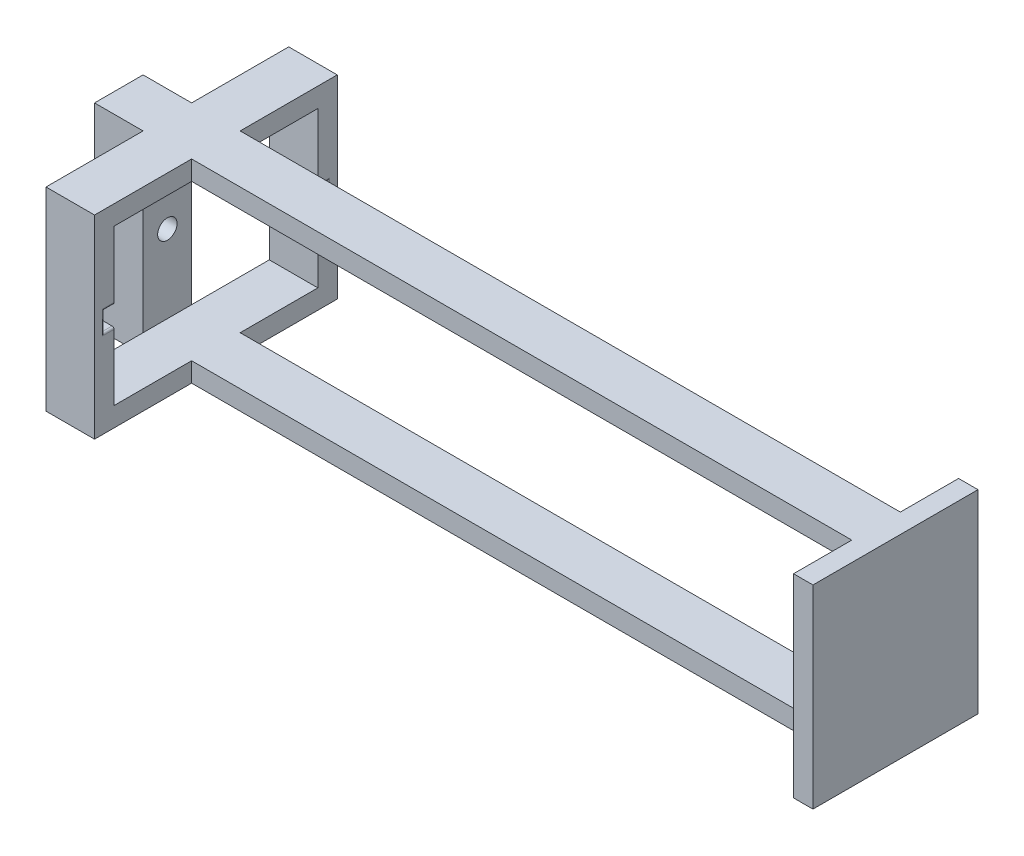
from build123d import *

# Parameters (mm, degrees)
SKETCH1_W            = 101.6
SKETCH1_H            = 25.4
BOSS_EXTRUDE1_DEPTH  = 3.175
BOSS_EXTRUDE2_DEPTH  = 6.35
SKETCH4_W            = 6.35
SKETCH4_H            = 2.54
CUT_EXTRUDE2_DEPTH   = 1.27
FILLET2_R            = 0.254
FILLET3_R            = 0.254
FILLET2_OF_MIRROR4_R = 0.254
FILLET3_OF_MIRROR4_R = 0.254
SKETCH6_W            = 7.62
SKETCH6_H            = 25.4
BOSS_EXTRUDE4_DEPTH  = 2.54
CUT_EXTRUDE3_REACH   = 21.05
SKETCH7_W            = 92.71
SKETCH7_H            = 20.32
CUT_EXTRUDE4_REACH   = 103.6
SKETCH8_R            = 1.27


with BuildPart() as part:
    # Sketch1 → Boss-Extrude1 (new body, symmetric)
    with BuildSketch(Plane.XY):
        with Locations((50.8, 0)):
            Rectangle(SKETCH1_W, SKETCH1_H)
    extrude(amount=BOSS_EXTRUDE1_DEPTH, both=True)

    # Sketch2 → Boss-Extrude2 (add)
    with BuildSketch(Plane.ZY.offset(-12.7)):
        Polygon((-3.175, 12.7), (-15.875, 12.7), (-15.875, -12.7), (-3.175, -12.7), (-3.175, -10.16), (-13.335, -10.16), (-13.335, 10.16), (-3.175, 10.16), align=None)
    boss_extrude2 = extrude(amount=BOSS_EXTRUDE2_DEPTH)

    # Sketch4 → Cut-Extrude2 (cut)
    with BuildSketch(Plane.XY.offset(-13.335)):
        with Locations((9.525, 0)):
            Rectangle(SKETCH4_W, SKETCH4_H)
    cut_extrude2 = extrude(amount=-CUT_EXTRUDE2_DEPTH, mode=Mode.SUBTRACT)

    # Fillet2
    fillet2_edges = [part.edges().sort_by_distance(p)[0] for p in [
        (6.35, 0, -14.605),
        (6.35, -1.27, -13.97),
        (6.35, 1.27, -13.97),
    ]]
    fillet(fillet2_edges, radius=FILLET2_R)

    # Fillet3
    fillet3_edges = [part.edges().sort_by_distance(p)[0] for p in [
        (12.7, 0, -14.605),
        (12.7, 1.27, -13.97),
        (12.7, -1.27, -13.97),
    ]]
    fillet(fillet3_edges, radius=FILLET3_R)

    # Mirror4: Boss-Extrude2, Cut-Extrude2 across plane
    add(boss_extrude2.mirror(Plane.XY))
    add(cut_extrude2.mirror(Plane.XY), mode=Mode.SUBTRACT)

    # Fillet2 of Mirror4
    fillet2_of_mirror4_edges = [part.edges().sort_by_distance(p)[0] for p in [
        (6.35, 0, 14.605),
        (6.35, -1.27, 13.97),
        (6.35, 1.27, 13.97),
    ]]
    fillet(fillet2_of_mirror4_edges, radius=FILLET2_OF_MIRROR4_R)

    # Fillet3 of Mirror4
    fillet3_of_mirror4_edges = [part.edges().sort_by_distance(p)[0] for p in [
        (12.7, 0, 14.605),
        (12.7, 1.27, 13.97),
        (12.7, -1.27, 13.97),
    ]]
    fillet(fillet3_of_mirror4_edges, radius=FILLET3_OF_MIRROR4_R)

    # Sketch6 → Boss-Extrude4 (add)
    with BuildSketch(Plane(origin=(101.6, 0, 0), x_dir=(0, 0, -1), z_dir=(1, 0, 0))):
        with Locations((6.985, 0)):
            Rectangle(SKETCH6_W, SKETCH6_H)
    boss_extrude4 = extrude(amount=-BOSS_EXTRUDE4_DEPTH)

    # Mirror5: Boss-Extrude4 across plane
    add(boss_extrude4.mirror(Plane.XY))

    # Sketch7 → Cut-Extrude3 (cut, up to next)
    with BuildSketch(Plane.XY.offset(3.175), mode=Mode.PRIVATE) as cut_extrude3_sk1:
        with Locations((52.705, 0)):
            Rectangle(SKETCH7_W, SKETCH7_H)
    cut_extrude3_tool1 = extrude(cut_extrude3_sk1.sketch, amount=-CUT_EXTRUDE3_REACH, mode=Mode.PRIVATE) & part.part
    add(cut_extrude3_tool1.solids().sort_by_distance((52.705, 0, 3.175))[0], mode=Mode.SUBTRACT)

    # Sketch8 → Cut-Extrude4 (cut, up to next)
    with BuildSketch(Plane.ZY, mode=Mode.PRIVATE) as cut_extrude4_sk1:
        Circle(SKETCH8_R)
    cut_extrude4_tool1 = extrude(cut_extrude4_sk1.sketch, amount=-CUT_EXTRUDE4_REACH, mode=Mode.PRIVATE) & part.part
    add(cut_extrude4_tool1.solids().sort_by_distance((0, 0, 0))[0], mode=Mode.SUBTRACT)


solid = part.part
